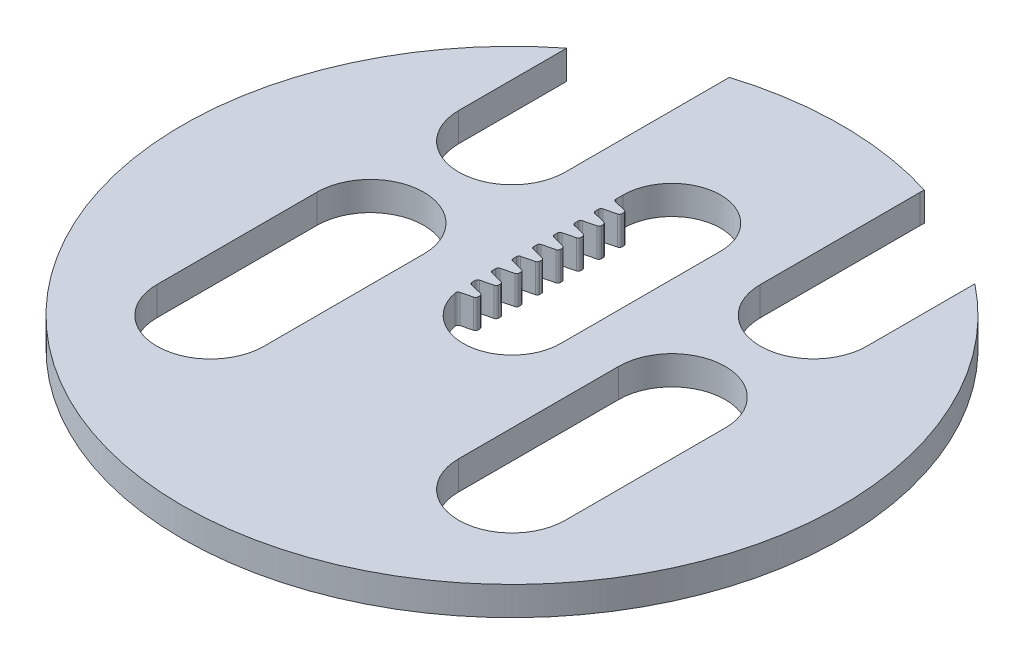
from build123d import *

# Parameters (mm, degrees)
BOSS_EXTRUDE1_DEPTH      = 3.175
BOSS_EXTRUDE1_DEPTH_BACK = 0.254
BOSS_EXTRUDE2_DEPTH      = 3.429
LPATTERN1_COUNT          = 8
LPATTERN1_PITCH          = 2.45
FILLET1_R                = 0.3


with BuildPart() as part:
    # Sketch3 → Boss-Extrude1 (new body, two sides)
    with BuildSketch(Plane.XZ) as boss_extrude1_sk:
        with BuildLine():
            ThreePointArc((39.2557, 0), (-17.127226966, 35.322345321), (-24.310512242, -30.822215641))
            Line((-24.310512242, -30.822215641), (-24.310512242, -17.960512242))
            ThreePointArc((-24.310512242, -17.960512242), (-17.960512242, -11.610512242), (-11.610512242, -17.960512242))
            Line((-11.610512242, -17.960512242), (-11.610512242, -37.010512242))
            ThreePointArc((-11.610512242, -37.010512242), (-11.615116608, -37.252285377), (-11.628923029, -37.493707894))
            ThreePointArc((-11.628923029, -37.493707894), (0, -39.2557), (11.628923029, -37.493707894))
            ThreePointArc((11.628923029, -37.493707894), (11.615116608, -37.252285377), (11.610512242, -37.010512242))
            Line((11.610512242, -37.010512242), (11.610512242, -17.960512242))
            ThreePointArc((11.610512242, -17.960512242), (17.960512242, -11.610512242), (24.310512242, -17.960512242))
            Line((24.310512242, -17.960512242), (24.310512242, -30.822215641))
            ThreePointArc((24.310512242, -30.822215641), (35.322345321, -17.127226966), (39.2557, 0))
        make_face()
        with BuildLine():
            ThreePointArc((-5.8, 0), (0, 5.8), (5.8, 0))
            Line((5.8, 0), (5.8, -19.05))
            ThreePointArc((5.8, -19.05), (0, -24.85), (-5.8, -19.05))
            Line((-5.8, -19.05), (-5.8, 0))
        make_face(mode=Mode.SUBTRACT)
        with BuildLine():
            ThreePointArc((-11.590512242, -1.089487758), (-17.960512242, -7.459487758), (-24.330512242, -1.089487758))
            Line((-24.330512242, -1.089487758), (-24.330512242, 17.960512242))
            ThreePointArc((-24.330512242, 17.960512242), (-17.960512242, 24.330512242), (-11.590512242, 17.960512242))
            Line((-11.590512242, 17.960512242), (-11.590512242, -1.089487758))
        make_face(mode=Mode.SUBTRACT)
        with BuildLine():
            ThreePointArc((24.310512242, -1.089487758), (17.960512242, -7.439487758), (11.610512242, -1.089487758))
            Line((11.610512242, -1.089487758), (11.610512242, 17.960512242))
            ThreePointArc((11.610512242, 17.960512242), (17.960512242, 24.310512242), (24.310512242, 17.960512242))
            Line((24.310512242, 17.960512242), (24.310512242, -1.089487758))
        make_face(mode=Mode.SUBTRACT)
    extrude(amount=BOSS_EXTRUDE1_DEPTH)
    extrude(boss_extrude1_sk.sketch, amount=-BOSS_EXTRUDE1_DEPTH_BACK)

    # Sketch4 → Boss-Extrude2 (add)
    with BuildSketch(Plane(origin=(0, 0.254, 0), x_dir=(1, 0, 0), z_dir=(0, 1, 0))):
        Polygon((-5.8, -0.803750085), (-3.94, -0.34), (-3.94, 0.34), (-5.8, 0.803750085), align=None)
    boss_extrude2 = extrude(amount=-BOSS_EXTRUDE2_DEPTH)

    # LPattern1: Boss-Extrude2 ×8
    with Locations(*[(0, 0, -i * LPATTERN1_PITCH) for i in range(1, LPATTERN1_COUNT)]):
        add(boss_extrude2)

    # Fillet1
    fillet1_edges = [part.edges().sort_by_distance(p)[0] for p in [
        (-3.94, -1.4605, 0.34),
        (-5.8, -1.4605, -0.803750085),
        (-3.94, -1.4605, -0.34),
        (-5.7459101, -1.4605, 0.790263959),
        (-5.8, -1.4605, -1.646249915),
        (-5.8, -1.4605, -3.253750085),
        (-3.94, -1.4605, -2.79),
        (-3.94, -1.4605, -2.11),
        (-5.8, -1.4605, -4.096249915),
        (-5.8, -1.4605, -5.703750085),
        (-3.94, -1.4605, -5.24),
        (-3.94, -1.4605, -4.56),
        (-5.8, -1.4605, -6.546249915),
        (-5.8, -1.4605, -8.153750085),
        (-3.94, -1.4605, -7.69),
        (-3.94, -1.4605, -7.01),
        (-5.8, -1.4605, -8.996249915),
        (-5.8, -1.4605, -10.603750085),
        (-3.94, -1.4605, -10.14),
        (-3.94, -1.4605, -9.46),
        (-5.8, -1.4605, -11.446249915),
        (-5.8, -1.4605, -13.053750085),
        (-3.94, -1.4605, -12.59),
        (-3.94, -1.4605, -11.91),
        (-5.8, -1.4605, -13.896249915),
        (-5.8, -1.4605, -15.503750085),
        (-3.94, -1.4605, -15.04),
        (-3.94, -1.4605, -14.36),
        (-5.8, -1.4605, -16.346249915),
        (-5.8, -1.4605, -17.953750085),
        (-3.94, -1.4605, -17.49),
        (-3.94, -1.4605, -16.81),
    ]]
    fillet(fillet1_edges, radius=FILLET1_R)


solid = part.part
